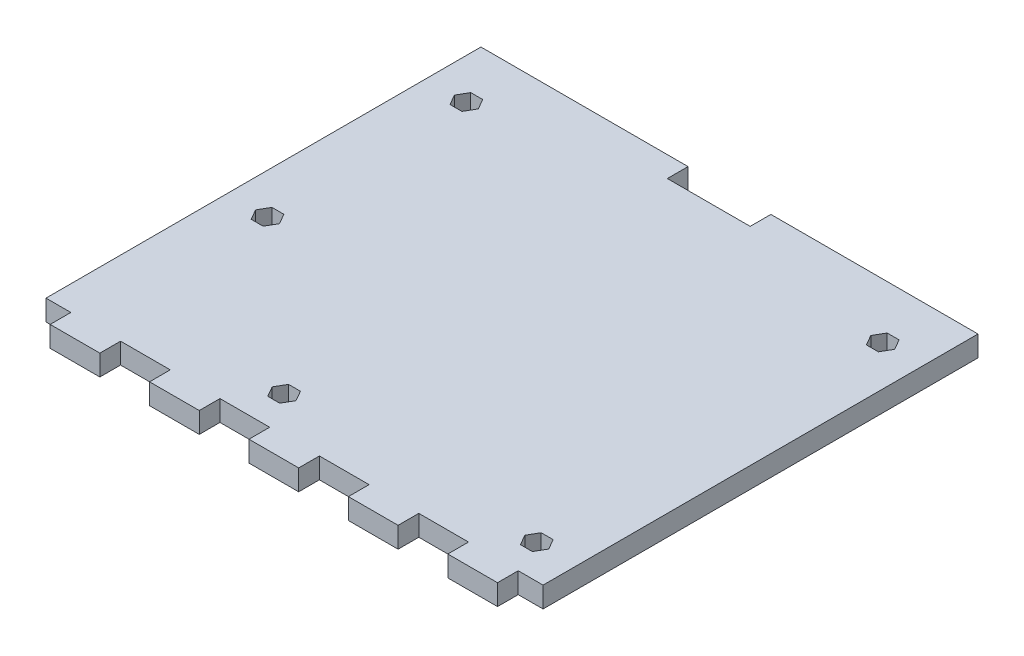
from build123d import *

# Parameters (mm, degrees)
BOSS_EXTRUDE2_DEPTH = 3.175


with BuildPart() as part:
    # Sketch1 → Boss-Extrude2 (new body)
    with BuildSketch(Plane(origin=(0, 0, 0), x_dir=(1, 0, 0), z_dir=(0, 1, 0))):
        Polygon((-19.05, -34.925), (-19.05, -31.75), (-26.67, -31.75), (-26.67, -34.925), (-34.29, -34.925), (-34.29, -31.75), (-38.1, -31.75), (-38.1, 34.925), (-6.35, 34.925), (-6.35, 31.75), (6.35, 31.75), (6.35, 34.925), (38.1, 34.925), (38.1, -31.75), (34.29, -31.75), (34.29, -34.925), (26.67, -34.925), (26.67, -31.75), (19.05, -31.75), (19.05, -34.925), (11.43, -34.925), (11.43, -31.75), (3.81, -31.75), (3.81, -34.925), (-3.81, -34.925), (-3.81, -31.75), (-11.43, -31.75), (-11.43, -34.925), align=None)
        Polygon((-30.998556448, -5.5626), (-30.082012895, -3.9751), (-30.998556448, -2.3876), (-32.831643552, -2.3876), (-33.748187105, -3.9751), (-32.831643552, -5.5626), align=None, mode=Mode.SUBTRACT)
        Polygon((-30.082012895, 26.5049), (-30.998556448, 28.0924), (-32.831643552, 28.0924), (-33.748187105, 26.5049), (-32.831643552, 24.9174), (-30.998556448, 24.9174), align=None, mode=Mode.SUBTRACT)
        Polygon((32.831643552, 24.9174), (33.748187105, 26.5049), (32.831643552, 28.0924), (30.998556448, 28.0924), (30.082012895, 26.5049), (30.998556448, 24.9174), align=None, mode=Mode.SUBTRACT)
        Polygon((-6.233556448, -27.7876), (-5.317012895, -26.2001), (-6.233556448, -24.6126), (-8.066643552, -24.6126), (-8.983187105, -26.2001), (-8.066643552, -27.7876), align=None, mode=Mode.SUBTRACT)
        Polygon((33.748187105, -26.5303), (32.831643552, -24.9428), (30.998556448, -24.9428), (30.082012895, -26.5303), (30.998556448, -28.1178), (32.831643552, -28.1178), align=None, mode=Mode.SUBTRACT)
    extrude(amount=BOSS_EXTRUDE2_DEPTH)


solid = part.part
